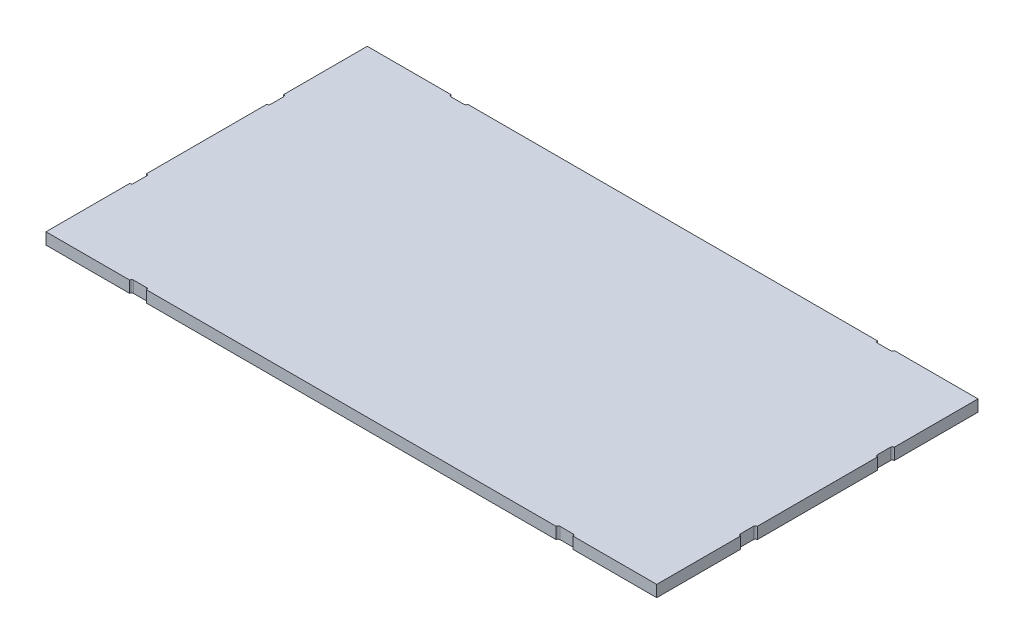
from build123d import *

# Parameters (mm, degrees)
SKETCH1_W           = 633
SKETCH1_H           = 333
BOSS_EXTRUDE1_DEPTH = 12
CUT_EXTRUDE1_DEPTH  = 13


with BuildPart() as part:
    # Sketch1 → Boss-Extrude1 (new body)
    with BuildSketch(Plane(origin=(0, 0, 0), x_dir=(1, 0, 0), z_dir=(0, 1, 0))):
        Rectangle(SKETCH1_W, SKETCH1_H)
    extrude(amount=BOSS_EXTRUDE1_DEPTH)

    # Sketch2 → Cut-Extrude1 (cut, through all)
    with BuildSketch(Plane(origin=(0, 12, 0), x_dir=(1, 0, 0), z_dir=(0, 1, 0))):
        with BuildLine():
            Line((-227.75, -164.5), (-214.25, -164.5))
            ThreePointArc((-214.25, -164.5), (-212.835786438, -165.085786438), (-212.25, -166.5))
            Line((-212.25, -166.5), (-212.25, -168.5))
            Line((-212.25, -168.5), (-229.75, -168.5))
            Line((-229.75, -168.5), (-229.75, -166.5))
            ThreePointArc((-229.75, -166.5), (-229.164213562, -165.085786438), (-227.75, -164.5))
        make_face()
        with BuildLine():
            Line((316.5, -62.25), (318.5, -62.25))
            Line((318.5, -62.25), (318.5, -79.75))
            Line((318.5, -79.75), (316.5, -79.75))
            ThreePointArc((316.5, -79.75), (315.085786438, -79.164213562), (314.5, -77.75))
            Line((314.5, -77.75), (314.5, -64.25))
            ThreePointArc((314.5, -64.25), (315.085786438, -62.835786438), (316.5, -62.25))
        make_face()
        with BuildLine():
            Line((212.25, -166.5), (212.25, -168.5))
            Line((212.25, -168.5), (229.75, -168.5))
            Line((229.75, -168.5), (229.75, -166.5))
            ThreePointArc((229.75, -166.5), (229.164213562, -165.085786438), (227.75, -164.5))
            Line((227.75, -164.5), (214.25, -164.5))
            ThreePointArc((214.25, -164.5), (212.835786438, -165.085786438), (212.25, -166.5))
        make_face()
        with BuildLine():
            Line((318.5, 62.25), (318.5, 79.75))
            Line((318.5, 79.75), (316.5, 79.75))
            ThreePointArc((316.5, 79.75), (315.085786438, 79.164213562), (314.5, 77.75))
            Line((314.5, 77.75), (314.5, 64.25))
            ThreePointArc((314.5, 64.25), (315.085786438, 62.835786438), (316.5, 62.25))
            Line((316.5, 62.25), (318.5, 62.25))
        make_face()
        with BuildLine():
            Line((-316.5, 62.25), (-318.5, 62.25))
            Line((-318.5, 62.25), (-318.5, 79.75))
            Line((-318.5, 79.75), (-316.5, 79.75))
            ThreePointArc((-316.5, 79.75), (-315.085786438, 79.164213562), (-314.5, 77.75))
            Line((-314.5, 77.75), (-314.5, 64.25))
            ThreePointArc((-314.5, 64.25), (-315.085786438, 62.835786438), (-316.5, 62.25))
        make_face()
        with BuildLine():
            Line((-318.5, -62.25), (-318.5, -79.75))
            Line((-318.5, -79.75), (-316.5, -79.75))
            ThreePointArc((-316.5, -79.75), (-315.085786438, -79.164213562), (-314.5, -77.75))
            Line((-314.5, -77.75), (-314.5, -64.25))
            ThreePointArc((-314.5, -64.25), (-315.085786438, -62.835786438), (-316.5, -62.25))
            Line((-316.5, -62.25), (-318.5, -62.25))
        make_face()
        with BuildLine():
            Line((227.75, 164.5), (214.25, 164.5))
            ThreePointArc((214.25, 164.5), (212.835786438, 165.085786438), (212.25, 166.5))
            Line((212.25, 166.5), (212.25, 168.5))
            Line((212.25, 168.5), (229.75, 168.5))
            Line((229.75, 168.5), (229.75, 166.5))
            ThreePointArc((229.75, 166.5), (229.164213562, 165.085786438), (227.75, 164.5))
        make_face()
        with BuildLine():
            Line((-212.25, 166.5), (-212.25, 168.5))
            Line((-212.25, 168.5), (-229.75, 168.5))
            Line((-229.75, 168.5), (-229.75, 166.5))
            ThreePointArc((-229.75, 166.5), (-229.164213562, 165.085786438), (-227.75, 164.5))
            Line((-227.75, 164.5), (-214.25, 164.5))
            ThreePointArc((-214.25, 164.5), (-212.835786438, 165.085786438), (-212.25, 166.5))
        make_face()
    extrude(amount=-CUT_EXTRUDE1_DEPTH, mode=Mode.SUBTRACT)


solid = part.part
